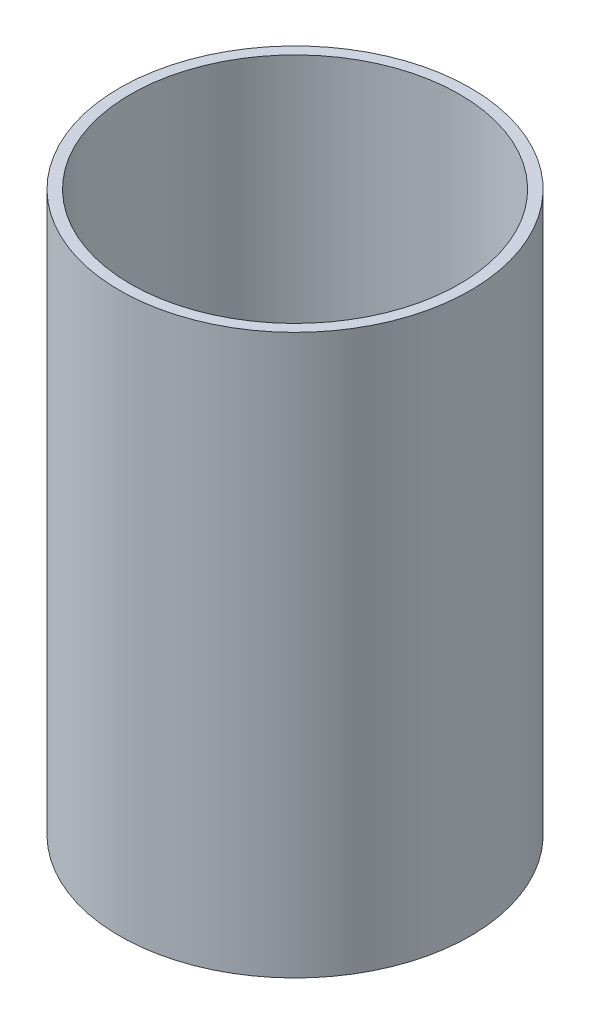
from build123d import *

# Parameters (mm, degrees)
SKETCH1_R           = 30
BOSS_EXTRUDE1_DEPTH = 100
SHELL1_T            = 2


with BuildPart() as part:
    # Sketch1 → Boss-Extrude1 (new body)
    with BuildSketch(Plane(origin=(0, 0, 0), x_dir=(1, 0, 0), z_dir=(0, 1, 0))):
        with Locations(Location((0, 0, 0), (0, 0, 90))):
            Circle(SKETCH1_R)
    extrude(amount=BOSS_EXTRUDE1_DEPTH)

    # Shell1
    shell1_openings = [part.faces().sort_by_distance(p)[0] for p in [
        (0, 100, 0),
    ]]
    offset(amount=SHELL1_T, openings=shell1_openings, kind=Kind.INTERSECTION)


solid = part.part
